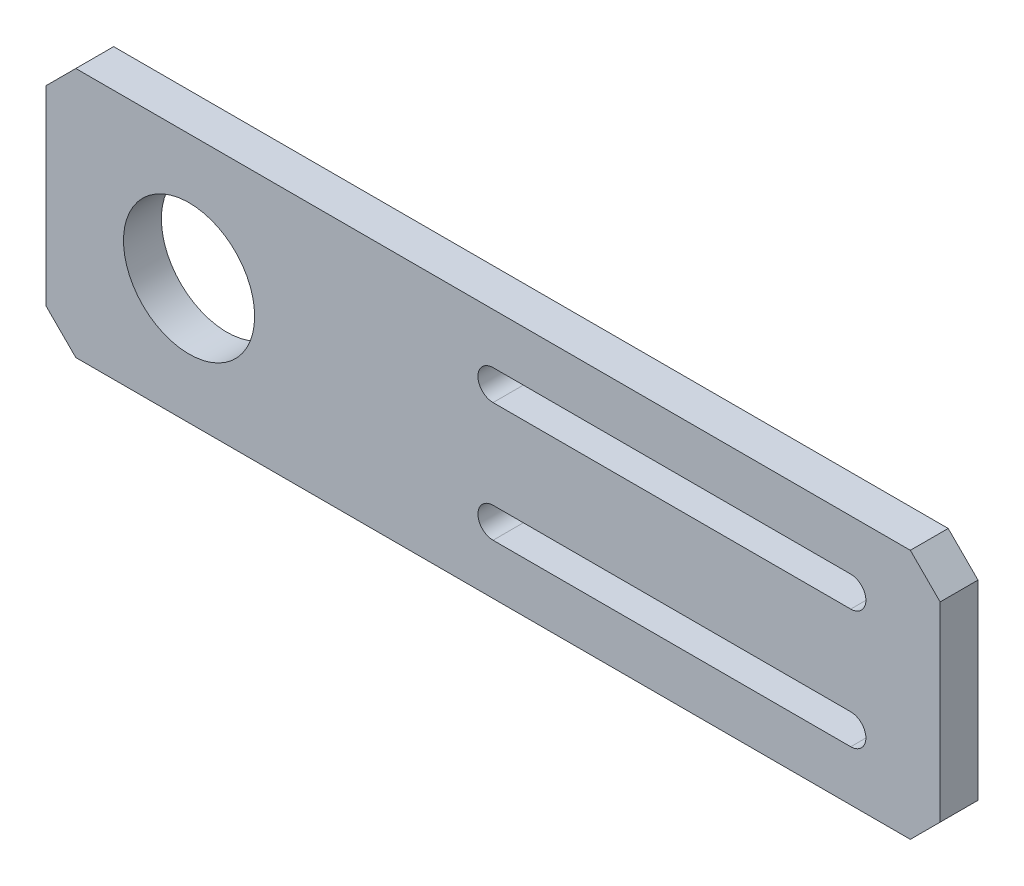
from build123d import *

# Parameters (mm, degrees)
SKETCH1_W           = 205
SKETCH1_H           = 42
BOSS_EXTRUDE1_DEPTH = 6.35
SKETCH4_R           = 11
CUT_EXTRUDE3_DEPTH  = 7.35
CHAMFER1_SIZE       = 5
SKETCH5_R           = 11
CUT_EXTRUDE4_DEPTH  = 25
SKETCH13_R          = 11
CUT_EXTRUDE12_DEPTH = 10


with BuildPart() as part:
    # Sketch1 → Boss-Extrude1 (new body)
    with BuildSketch(Plane.XY):
        Rectangle(SKETCH1_W, SKETCH1_H)
    extrude(amount=BOSS_EXTRUDE1_DEPTH)

    # Sketch4 → Cut-Extrude3 (cut, through all)
    with BuildSketch(Plane.XY.offset(6.35)):
        with Locations((-78.5, 0)):
            Circle(SKETCH4_R)
    extrude(amount=-CUT_EXTRUDE3_DEPTH, mode=Mode.SUBTRACT)

    # Chamfer1
    chamfer1_edges = [part.edges().sort_by_distance(p)[0] for p in [
        (102.5, -21, 3.175),
        (-102.5, -21, 3.175),
        (-102.5, 21, 3.175),
        (102.5, 21, 3.175),
    ]]
    chamfer(chamfer1_edges, length=CHAMFER1_SIZE)

    # Sketch5 → Cut-Extrude4 (cut)
    with BuildSketch(Plane.XY.offset(6.35)):
        with Locations((79.5, 0)):
            Circle(SKETCH5_R)
    extrude(amount=-CUT_EXTRUDE4_DEPTH, mode=Mode.SUBTRACT)

    # Sketch13 → Cut-Extrude12 (cut)
    with BuildSketch(Plane.XY.offset(6.35)):
        Polygon((42.5, 21), (47.5, 16), (47.5, -16), (42.5, -21), (97.5, -21), (102.5, -16), (102.5, 16), (97.5, 21), align=None)
        with Locations((79.5, 0)):
            Circle(SKETCH13_R, mode=Mode.SUBTRACT)
        with BuildLine():
            Line((-27.5, 7.46), (32.5, 7.46))
            ThreePointArc((32.5, 7.46), (35.04, 10), (32.5, 12.54))
            Line((32.5, 12.54), (-27.5, 12.54))
            ThreePointArc((-27.5, 12.54), (-30.04, 10), (-27.5, 7.46))
        make_face()
        with BuildLine():
            ThreePointArc((32.5, -7.46), (35.04, -10), (32.5, -12.54))
            Line((32.5, -12.54), (-27.5, -12.54))
            ThreePointArc((-27.5, -12.54), (-30.04, -10), (-27.5, -7.46))
            Line((-27.5, -7.46), (32.5, -7.46))
        make_face()
    extrude(amount=-CUT_EXTRUDE12_DEPTH, mode=Mode.SUBTRACT)


solid = part.part
